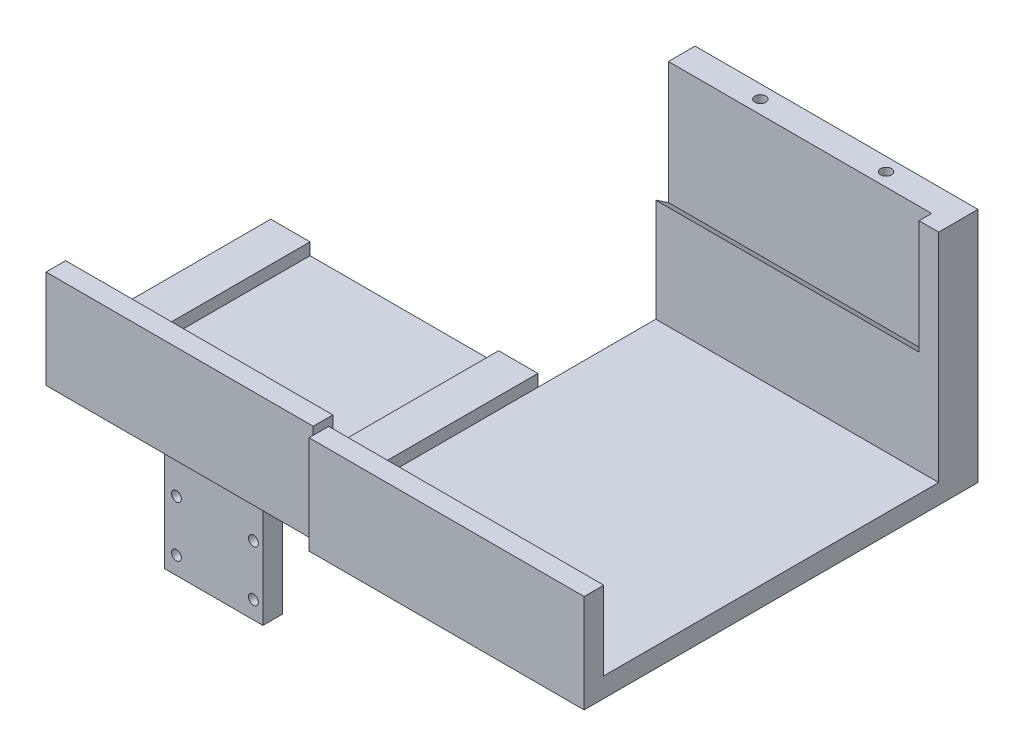
from build123d import *

# Parameters (mm, degrees)
SKETCH1_W                 = 25
SKETCH1_H                 = 38
BOSS_EXTRUDE1_DEPTH       = 12
SKETCH3_W                 = 25
SKETCH3_H                 = 12
BOSS_EXTRUDE2_DEPTH       = 5.5
SKETCH5_W                 = 25
SKETCH5_H                 = 5
BOSS_EXTRUDE3_DEPTH       = 21
SKETCH6_R                 = 1.25
CUT_EXTRUDE1_DEPTH        = 10
SKETCH7_W                 = 210
SKETCH7_H                 = 85.25
BOSS_EXTRUDE4_DEPTH       = 5
SKETCH8_W                 = 10
SKETCH8_H                 = 60.2
BOSS_EXTRUDE5_DEPTH       = 210
CUT_EXTRUDE3_DEPTH        = 211
BOSS_EXTRUDE6_DEPTH       = 5
SKETCH11_W                = 10
SKETCH11_H                = 85.25
BOSS_EXTRUDE7_DEPTH       = 3.05
SKETCH12_W                = 10
SKETCH12_H                = 50
BOSS_EXTRUDE8_DEPTH       = 10.45
SKETCH13_W                = 70
SKETCH13_H                = 25
BOSS_EXTRUDE9_DEPTH       = 5
SKETCH14_W                = 68
SKETCH14_H                = 25
BOSS_EXTRUDE10_DEPTH      = 1.95
BOSS_EXTRUDE10_DEPTH_BACK = 3.05
SKETCH18_W                = 95.25
SKETCH18_H                = 60.2
CUT_EXTRUDE5_DEPTH        = 70
SKETCH19_W                = 68
SKETCH19_H                = 40
CUT_EXTRUDE6_DEPTH        = 94.2
SKETCH20_R                = 1.3890625
CUT_EXTRUDE7_DEPTH        = 10


with BuildPart() as part:
    # Sketch1 → Boss-Extrude1 (new body)
    with BuildSketch(Plane(origin=(0, 0, 0), x_dir=(1, 0, 0), z_dir=(0, 1, 0))):
        with Locations((12.5, 19)):
            Rectangle(SKETCH1_W, SKETCH1_H)
    extrude(amount=BOSS_EXTRUDE1_DEPTH)

    # Sketch3 → Boss-Extrude2 (add)
    with BuildSketch(Plane.XY):
        with Locations((12.5, 6)):
            Rectangle(SKETCH3_W, SKETCH3_H)
    boss_extrude2 = extrude(amount=BOSS_EXTRUDE2_DEPTH)

    # Sketch5 → Boss-Extrude3 (add)
    with BuildSketch(Plane.XZ):
        with Locations((12.5, 3)):
            Rectangle(SKETCH5_W, SKETCH5_H)
    boss_extrude3 = extrude(amount=BOSS_EXTRUDE3_DEPTH)

    # Sketch6 → Cut-Extrude1 (cut)
    with BuildSketch(Plane.XY.offset(5.5)):
        with Locations((3, -16.5)):
            Circle(SKETCH6_R)
        with Locations((22.59, -16.5)):
            Circle(SKETCH6_R)
        with Locations((22.59, -3.53)):
            Circle(SKETCH6_R)
        with Locations((3, -3.53)):
            Circle(SKETCH6_R)
    cut_extrude1 = extrude(amount=-CUT_EXTRUDE1_DEPTH, mode=Mode.SUBTRACT)

    # Mirror1: Boss-Extrude2, Boss-Extrude3, Cut-Extrude1 across plane
    add(boss_extrude2.mirror(Plane.XY.offset(-19)))
    add(boss_extrude3.mirror(Plane.XY.offset(-19)))
    add(cut_extrude1.mirror(Plane.XY.offset(-19)), mode=Mode.SUBTRACT)

    # Sketch7 → Boss-Extrude4 (add)
    with BuildSketch(Plane(origin=(0, 12, 0), x_dir=(1, 0, 0), z_dir=(0, 1, 0))):
        with Locations((12.5, 31.375)):
            Rectangle(SKETCH7_W, SKETCH7_H)
    extrude(amount=BOSS_EXTRUDE4_DEPTH)

    # Sketch8 → Boss-Extrude5 (add, through all)
    with BuildSketch(Plane(origin=(117.5, 0, 0), x_dir=(0, 0, -1), z_dir=(1, 0, 0))):
        with Locations((79, 42.1)):
            Rectangle(SKETCH8_W, SKETCH8_H)
    extrude(amount=-BOSS_EXTRUDE5_DEPTH)

    # Sketch9 → Cut-Extrude3 (cut, through all)
    with BuildSketch(Plane.ZY.offset(92.5)):
        Polygon((-74, 43.24), (-77.2, 41.128), (-77.2, 72.2), (-74, 72.2), align=None)
    extrude(amount=-CUT_EXTRUDE3_DEPTH, mode=Mode.SUBTRACT)

    # Sketch10 → Boss-Extrude6 (add)
    with BuildSketch(Plane(origin=(117.5, 0, 0), x_dir=(0, 0, -1), z_dir=(1, 0, 0))):
        Polygon((77.2, 72.2), (74, 72.2), (74, 43.24), (77.2, 41.128), align=None)
    extrude(amount=-BOSS_EXTRUDE6_DEPTH)

    # Sketch11 → Boss-Extrude7 (add)
    with BuildSketch(Plane(origin=(0, 17, 0), x_dir=(1, 0, 0), z_dir=(0, 1, 0))):
        with Locations((40.5, 31.375)):
            Rectangle(SKETCH11_W, SKETCH11_H)
        with Locations((-17.5, 31.375)):
            Rectangle(SKETCH11_W, SKETCH11_H)
    extrude(amount=BOSS_EXTRUDE7_DEPTH)

    # Sketch12 → Boss-Extrude8 (add)
    with BuildSketch(Plane(origin=(0, 17, 0), x_dir=(1, 0, 0), z_dir=(0, 1, 0))):
        with Locations((-87.5, 31.375)):
            Rectangle(SKETCH12_W, SKETCH12_H)
        with Locations((-37.5, 31.375)):
            Rectangle(SKETCH12_W, SKETCH12_H)
    extrude(amount=BOSS_EXTRUDE8_DEPTH)

    # Sketch13 → Boss-Extrude9 (add)
    with BuildSketch(Plane.XY.offset(11.25)):
        with Locations((82.5, 24.5)):
            Rectangle(SKETCH13_W, SKETCH13_H)
    extrude(amount=BOSS_EXTRUDE9_DEPTH)

    # Sketch14 → Boss-Extrude10 (add, two sides)
    with BuildSketch(Plane.XY.offset(11.25)) as boss_extrude10_sk:
        with Locations((11.5, 24.5)):
            Rectangle(SKETCH14_W, SKETCH14_H)
    extrude(amount=BOSS_EXTRUDE10_DEPTH)
    extrude(boss_extrude10_sk.sketch, amount=-BOSS_EXTRUDE10_DEPTH_BACK)

    # Sketch18 → Cut-Extrude5 (cut)
    with BuildSketch(Plane.ZY.offset(92.5)):
        with Locations((-36.375, 42.1)):
            Rectangle(SKETCH18_W, SKETCH18_H)
    extrude(amount=-CUT_EXTRUDE5_DEPTH, mode=Mode.SUBTRACT)

    # Sketch19 → Cut-Extrude6 (cut, through all)
    with BuildSketch(Plane(origin=(0, 72.2, 0), x_dir=(1, 0, 0), z_dir=(0, 1, 0))):
        with Locations((11.5, 64)):
            Rectangle(SKETCH19_W, SKETCH19_H)
    extrude(amount=-CUT_EXTRUDE6_DEPTH, mode=Mode.SUBTRACT)

    # Sketch20 → Cut-Extrude7 (cut)
    with BuildSketch(Plane(origin=(0, 72.2, 0), x_dir=(1, 0, 0), z_dir=(0, 1, 0))):
        with Locations((65.5, 80.6)):
            Circle(SKETCH20_R)
        with Locations((97.5, 80.6)):
            Circle(SKETCH20_R)
    extrude(amount=-CUT_EXTRUDE7_DEPTH, mode=Mode.SUBTRACT)


solid = part.part
